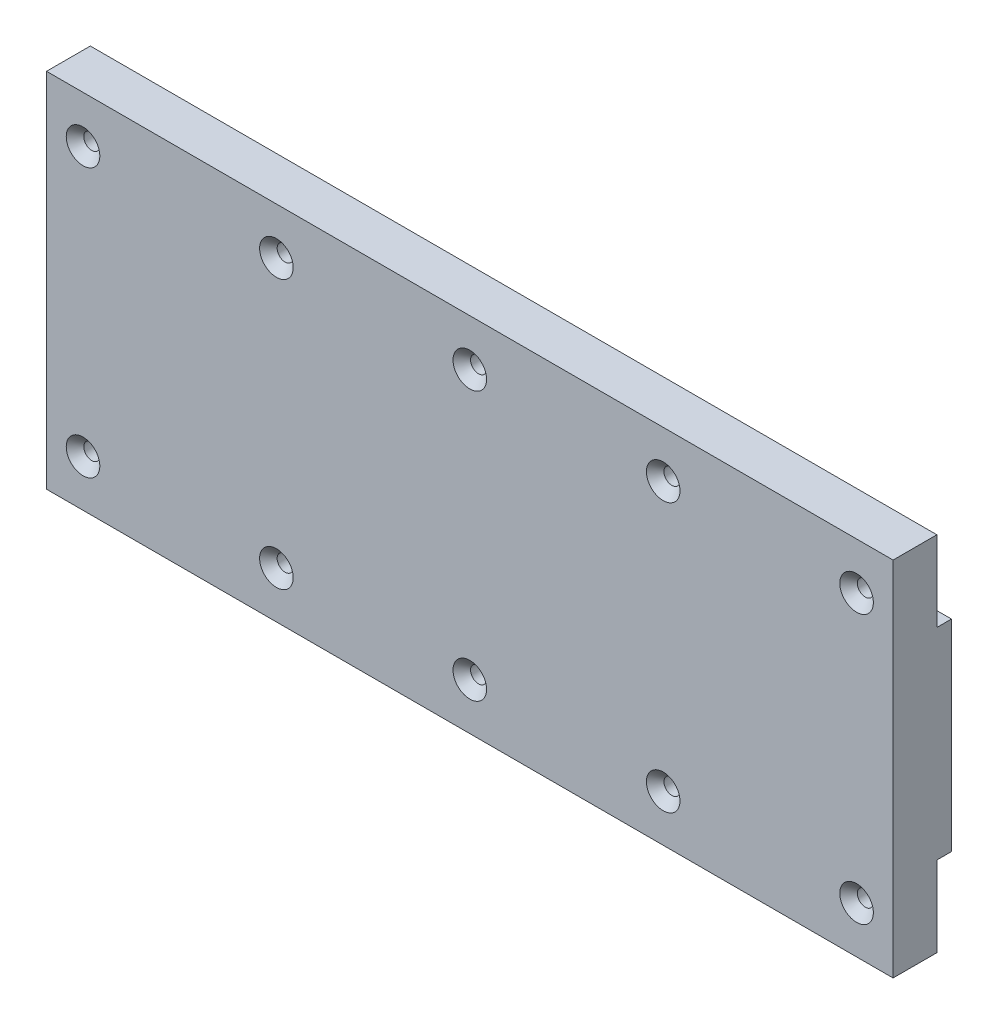
from build123d import *

# Parameters (mm, degrees)
SALIENTE_EXTRUIR1_DEPTH = 580
CROQUIS3_R              = 5.5
CORTAR_EXTRUIR1_DEPTH   = 580
CHAFL_N2_SIZE           = 6


with BuildPart() as part:
    # Croquis2 → Saliente-Extruir1 (new body)
    with BuildSketch(Plane(origin=(0, 0, 0), x_dir=(0, 0, -1), z_dir=(1, 0, 0))):
        Polygon((0, 0), (0, 248), (30, 248), (30, 193), (40, 193), (40, 55), (30, 55), (30, 0), align=None)
    extrude(amount=SALIENTE_EXTRUIR1_DEPTH)

    # Croquis3 → Cortar-Extruir1 (cut)
    with BuildSketch(Plane.XY):
        with Locations((25, 216)):
            Circle(CROQUIS3_R)
        with Locations((25, 32)):
            Circle(CROQUIS3_R)
        with Locations((157.5, 216)):
            Circle(CROQUIS3_R)
        with Locations((157.5, 32)):
            Circle(CROQUIS3_R)
        with Locations((290, 216)):
            Circle(CROQUIS3_R)
        with Locations((290, 32)):
            Circle(CROQUIS3_R)
        with Locations((422.5, 216)):
            Circle(CROQUIS3_R)
        with Locations((422.5, 32)):
            Circle(CROQUIS3_R)
        with Locations((555, 216)):
            Circle(CROQUIS3_R)
        with Locations((555, 32)):
            Circle(CROQUIS3_R)
    extrude(amount=-CORTAR_EXTRUIR1_DEPTH, mode=Mode.SUBTRACT)

    # Chaflán2
    chafl_n2_edges = [part.edges().sort_by_distance(p)[0] for p in [
        (284.5, 32, 0),
        (417, 216, 0),
        (417, 32, 0),
        (549.5, 216, 0),
        (19.5, 32, 0),
        (152, 216, 0),
        (152, 32, 0),
        (284.5, 216, 0),
        (549.5, 32, 0),
        (19.5, 216, 0),
    ]]
    chamfer(chafl_n2_edges, length=CHAFL_N2_SIZE)


solid = part.part
